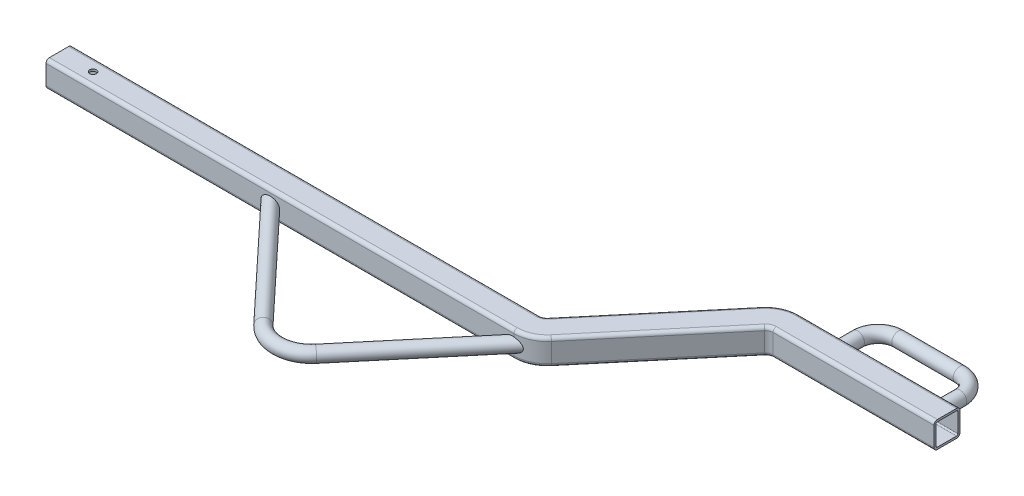
from build123d import *

# Parameters (mm, degrees)
CUT_EXTRUDE3_DEPTH      = 1131.639859977
CUT_EXTRUDE3_DEPTH_BACK = 1131.639859977
SKETCH21_R              = 5
SWEEP_THIN4_PROFILE_R   = 10
SWEEP_THIN4_PROFILE_R_2 = 7
SWEEP_THIN5_PROFILE_R   = 10
SWEEP_THIN5_PROFILE_R_2 = 9


with BuildPart() as part:
    # Sweep-Thin3: sweep along a curve in space
    with BuildLine() as sweep_thin3_path:
        Line((874.686132166, 0, -191.51111078), (1110.696902422, 0, -191.51111078))
        ThreePointArc((851.704798873, 0, -180.79473907), (862.007584314, 0, -188.700344391), (874.686132166, 0, -191.51111078))
        Line((708.992103549, 0, -10.716371709), (851.704798873, 0, -180.79473907))
        ThreePointArc((686.010770255, 0, 0), (698.689318108, 0, -2.810766389), (708.992103549, 0, -10.716371709))
        Line((0, 0, 0), (686.010770255, 0, 0))
    # Sketch2 → Sweep-Thin3 (sweep)
    with BuildSketch(Plane(origin=(0, 0, 0), x_dir=(0, 0, -1), z_dir=(1, 0, 0))):
        with BuildLine():
            Line((14.05, 19.05), (-14.05, 19.05))
            ThreePointArc((-14.05, 19.05), (-17.585533906, 17.585533906), (-19.05, 14.05))
            Line((-19.05, 14.05), (-19.05, -14.05))
            ThreePointArc((-19.05, -14.05), (-17.585533906, -17.585533906), (-14.05, -19.05))
            Line((-14.05, -19.05), (14.05, -19.05))
            ThreePointArc((14.05, -19.05), (17.585533906, -17.585533906), (19.05, -14.05))
            Line((19.05, -14.05), (19.05, 14.05))
            ThreePointArc((19.05, 14.05), (17.585533906, 17.585533906), (14.05, 19.05))
        make_face()
        with BuildLine():
            Line((14.05, 16.05), (-14.05, 16.05))
            ThreePointArc((-14.05, 16.05), (-15.464213562, 15.464213562), (-16.05, 14.05))
            Line((-16.05, 14.05), (-16.05, -14.05))
            ThreePointArc((-16.05, -14.05), (-15.464213562, -15.464213562), (-14.05, -16.05))
            Line((-14.05, -16.05), (14.05, -16.05))
            ThreePointArc((14.05, -16.05), (15.464213562, -15.464213562), (16.05, -14.05))
            Line((16.05, -14.05), (16.05, 14.05))
            ThreePointArc((16.05, 14.05), (15.464213562, 15.464213562), (14.05, 16.05))
        make_face(mode=Mode.SUBTRACT)
    sweep(path=sweep_thin3_path.line)

    # Sketch21 → Cut-Extrude3 (cut, two sides: drawn at the far end of the back side and taken through both)
    with BuildSketch(Plane(origin=(0, 0, 0), x_dir=(1, 0, 0), z_dir=(0, 1, 0)).offset(-CUT_EXTRUDE3_DEPTH_BACK)):
        with Locations((50, 0)):
            Circle(SKETCH21_R)
    extrude(amount=CUT_EXTRUDE3_DEPTH + CUT_EXTRUDE3_DEPTH_BACK, mode=Mode.SUBTRACT)

    # Sweep-Thin4: sweep along a path in Sketch25
    with BuildLine(Plane.XZ) as sweep_thin4_path:
        Line((1080.696902422, -210.56111078), (1080.696902422, -240.56111078))
        ThreePointArc((1080.696902422, -240.56111078), (1071.910105857, -261.774314215), (1050.696902422, -270.56111078))
        Line((1050.696902422, -270.56111078), (960.696902422, -270.56111078))
        ThreePointArc((960.696902422, -270.56111078), (939.483698986, -261.774314215), (930.696902422, -240.56111078))
        Line((930.696902422, -240.56111078), (930.696902422, -210.56111078))
    # Sweep-Thin4 profile (on start of the path) → Sweep-Thin4 (sweep)
    with BuildSketch(Plane(origin=(1080.696902422, 0, -210.56111078), x_dir=(-1, 0, 0), z_dir=(0, 0, -1))):
        Circle(SWEEP_THIN4_PROFILE_R)
        Circle(SWEEP_THIN4_PROFILE_R_2, mode=Mode.SUBTRACT)
    sweep(path=sweep_thin4_path.line)

    # Sweep-Thin5: sweep along a path in Sketch26
    with BuildLine(Plane(origin=(0, 0, 0), x_dir=(1, 0, 0), z_dir=(0, 1, 0))) as sweep_thin5_path:
        Line((708.992103549, 10.716371709), (552.427571648, -175.869971657))
        ThreePointArc((552.427571648, -175.869971657), (515.471927983, -193.712455147), (477.609189287, -177.885679284))
        Line((477.609189287, -177.885679284), (311.225291972, 0))
    # Sweep-Thin5 profile (on start of the path) → Sweep-Thin5 (sweep)
    with BuildSketch(Plane(origin=(708.992103549, 0, -10.716371709), x_dir=(0.7660444431189789, 0, 0.6427876096865383), z_dir=(-0.6427876096865383, 0, 0.7660444431189789))):
        Circle(SWEEP_THIN5_PROFILE_R)
        Circle(SWEEP_THIN5_PROFILE_R_2, mode=Mode.SUBTRACT)
    sweep(path=sweep_thin5_path.line)


solid = part.part
